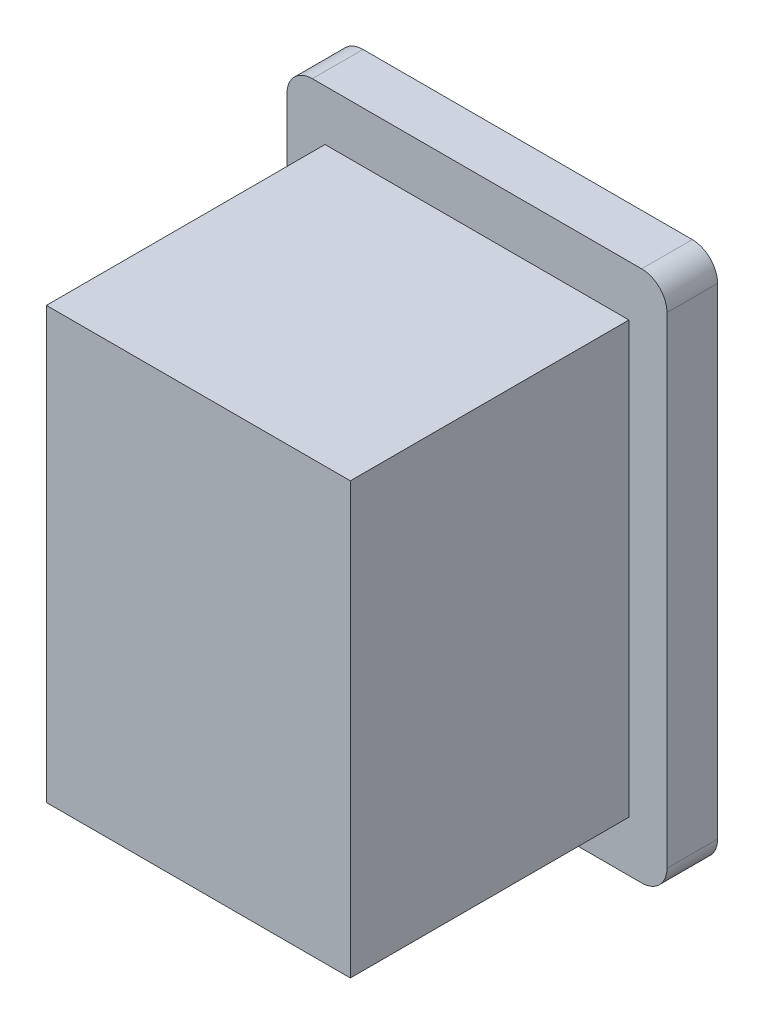
from build123d import *

# Parameters (mm, degrees)
SKETCH1_W           = 12
SKETCH1_H           = 17
BOSS_EXTRUDE1_DEPTH = 13
SKETCH2_W           = 15
SKETCH2_H           = 21
BOSS_EXTRUDE2_DEPTH = 2
FILLET1_R           = 1


with BuildPart() as part:
    # Sketch1 → Boss-Extrude1 (new body)
    with BuildSketch(Plane.XY):
        Rectangle(SKETCH1_W, SKETCH1_H)
    extrude(amount=BOSS_EXTRUDE1_DEPTH)

    # Sketch2 → Boss-Extrude2 (add)
    with BuildSketch(Plane.XY):
        Rectangle(SKETCH2_W, SKETCH2_H)
    extrude(amount=BOSS_EXTRUDE2_DEPTH)

    # Fillet1
    fillet1_edges = [part.edges().sort_by_distance(p)[0] for p in [
        (-7.5, 10.5, 1),
        (-7.5, -10.5, 1),
        (7.5, -10.5, 1),
        (7.5, 10.5, 1),
    ]]
    fillet(fillet1_edges, radius=FILLET1_R)


solid = part.part
